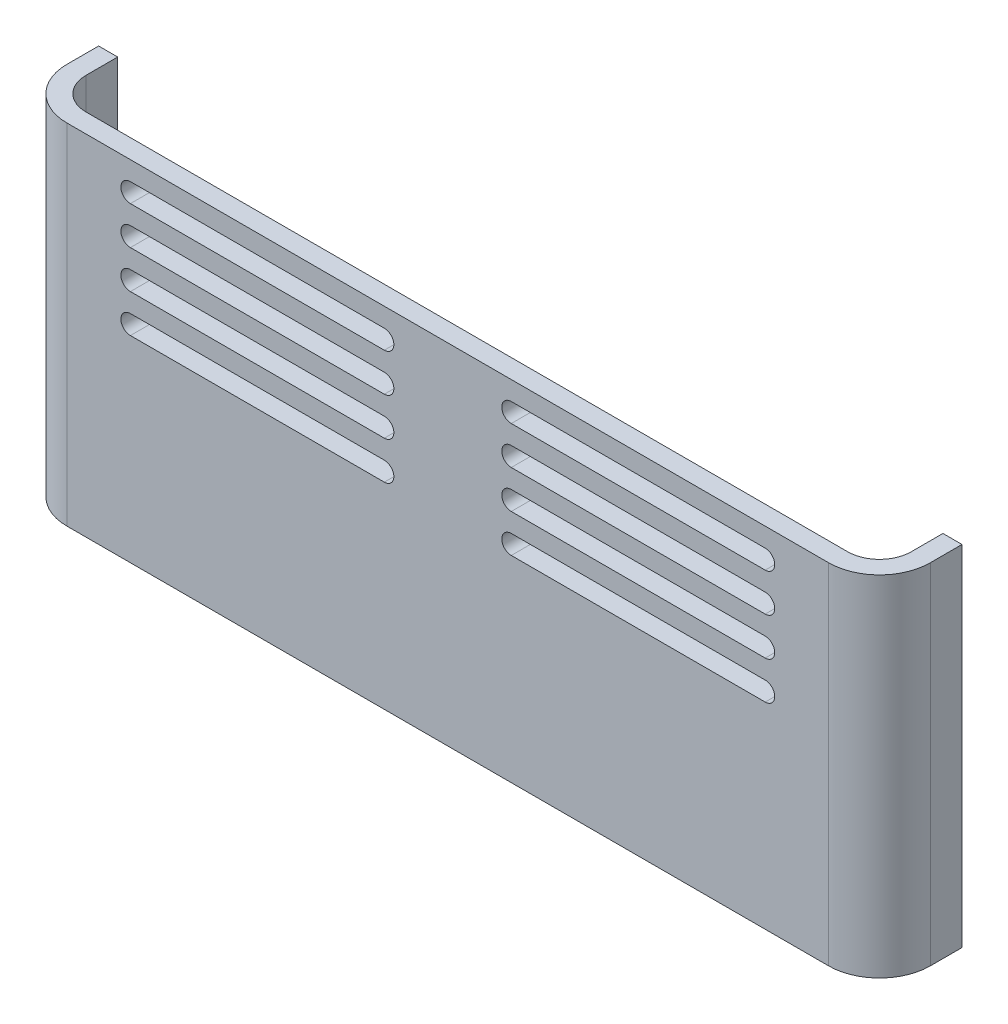
from build123d import *

# Parameters (mm, degrees)
BOSS_EXTRUDE1_DEPTH = 55
BOSS_EXTRUDE2_START = 15
SKETCH2_R           = 5
SKETCH2_R_2         = 2.75
BOSS_EXTRUDE2_DEPTH = 6
CUT_EXTRUDE1_START  = 15
SKETCH2_4_R         = 2.75
CUT_EXTRUDE1_DEPTH  = 4
SKETCH3_W           = 40
SKETCH3_H           = 3
CUT_EXTRUDE2_DEPTH  = 10
BOSS_EXTRUDE3_START = 15
SKETCH2_5_R         = 2.75
BOSS_EXTRUDE3_DEPTH = 1


with BuildPart() as part:
    # Sketch1 → Boss-Extrude1 (new body)
    with BuildSketch(Plane(origin=(0, 0, 0), x_dir=(1, 0, 0), z_dir=(0, 1, 0))):
        with BuildLine():
            Line((-3, 5), (-3, 10))
            Line((-3, 10), (0, 10))
            Line((0, 10), (0, 5))
            ThreePointArc((0, 5), (1.464466094, 1.464466094), (5, 0))
            Line((5, 0), (125, 0))
            ThreePointArc((125, 0), (128.535533906, 1.464466094), (130, 5))
            Line((130, 5), (130, 10))
            Line((130, 10), (133, 10))
            Line((133, 10), (133, 5))
            ThreePointArc((133, 5), (130.656854249, -0.656854249), (125, -3))
            Line((125, -3), (5, -3))
            ThreePointArc((5, -3), (-0.656854249, -0.656854249), (-3, 5))
        make_face()
    extrude(amount=BOSS_EXTRUDE1_DEPTH)

    # Sketch2 → Boss-Extrude2 (add)
    with BuildSketch(Plane(origin=(0, 0, 0), x_dir=(1, 0, 0), z_dir=(0, 1, 0)).offset(BOSS_EXTRUDE2_START)):
        with BuildLine():
            Line((5, 10), (0, 10))
            Line((0, 10), (0, 5))
            ThreePointArc((0, 5), (1.464466094, 8.535533906), (5, 10))
        make_face()
        with Locations((5, 5)):
            Circle(SKETCH2_R)
        with Locations((5, 5)):
            Circle(SKETCH2_R_2, mode=Mode.SUBTRACT)
        with BuildLine():
            Line((10, 0), (10, 5))
            ThreePointArc((10, 5), (8.535533906, 1.464466094), (5, 0))
            Line((5, 0), (10, 0))
        make_face()
        with BuildLine():
            Line((120, 5), (120, 0))
            Line((120, 0), (125, 0))
            ThreePointArc((125, 0), (121.464466094, 1.464466094), (120, 5))
        make_face()
        with Locations((125, 5)):
            Circle(SKETCH2_R)
        with Locations((125, 5)):
            Circle(SKETCH2_R_2, mode=Mode.SUBTRACT)
        with Locations((125, 5)):
            Circle(SKETCH2_R_2)
        with BuildLine():
            ThreePointArc((125, 10), (128.535533906, 8.535533906), (130, 5))
            Line((130, 5), (130, 10))
            Line((130, 10), (125, 10))
        make_face()
        with Locations((5, 5)):
            Circle(SKETCH2_R_2)
    extrude(amount=BOSS_EXTRUDE2_DEPTH)

    # Sketch2_4 → Cut-Extrude1 (cut)
    with BuildSketch(Plane(origin=(0, 0, 0), x_dir=(1, 0, 0), z_dir=(0, 1, 0)).offset(CUT_EXTRUDE1_START)):
        with Locations((5, 5)):
            Circle(SKETCH2_4_R)
        with Locations((125, 5)):
            Circle(SKETCH2_4_R)
    extrude(amount=CUT_EXTRUDE1_DEPTH, mode=Mode.SUBTRACT)

    # Sketch3 → Cut-Extrude2 (cut)
    with BuildSketch(Plane.XY):
        with BuildLine():
            ThreePointArc((55, 40), (56.5, 38.5), (55, 37))
            Line((55, 37), (15, 37))
            ThreePointArc((15, 37), (13.5, 38.5), (15, 40))
            Line((15, 40), (55, 40))
        make_face()
        with BuildLine():
            ThreePointArc((55, 46), (56.5, 44.5), (55, 43))
            Line((55, 43), (15, 43))
            ThreePointArc((15, 43), (13.5, 44.5), (15, 46))
            Line((15, 46), (55, 46))
        make_face()
        with BuildLine():
            Line((115, 37), (75, 37))
            ThreePointArc((75, 37), (73.5, 38.5), (75, 40))
            Line((75, 40), (115, 40))
            ThreePointArc((115, 40), (116.5, 38.5), (115, 37))
        make_face()
        with BuildLine():
            Line((115, 43), (75, 43))
            ThreePointArc((75, 43), (73.5, 44.5), (75, 46))
            Line((75, 46), (115, 46))
            ThreePointArc((115, 46), (116.5, 44.5), (115, 43))
        make_face()
        with Locations((95, 50.5)):
            Rectangle(SKETCH3_W, SKETCH3_H)
        with Locations((35, 50.5)):
            Rectangle(SKETCH3_W, SKETCH3_H)
        with BuildLine():
            ThreePointArc((15, 49), (13.5, 50.5), (15, 52))
            Line((15, 52), (15, 49))
        make_face()
        with BuildLine():
            ThreePointArc((55, 52), (56.5, 50.5), (55, 49))
            Line((55, 49), (55, 52))
        make_face()
        with BuildLine():
            Line((75, 52), (75, 49))
            ThreePointArc((75, 49), (73.5, 50.5), (75, 52))
        make_face()
        with BuildLine():
            Line((115, 52), (115, 49))
            ThreePointArc((115, 49), (116.5, 50.5), (115, 52))
        make_face()
        with BuildLine():
            ThreePointArc((55, 34), (56.5, 32.5), (55, 31))
            Line((55, 31), (15, 31))
            ThreePointArc((15, 31), (13.5, 32.5), (15, 34))
            Line((15, 34), (55, 34))
        make_face()
        with BuildLine():
            Line((115, 31), (75, 31))
            ThreePointArc((75, 31), (73.5, 32.5), (75, 34))
            Line((75, 34), (115, 34))
            ThreePointArc((115, 34), (116.5, 32.5), (115, 31))
        make_face()
    extrude(amount=CUT_EXTRUDE2_DEPTH, mode=Mode.SUBTRACT)

    # Sketch2_5 → Boss-Extrude3 (add)
    with BuildSketch(Plane(origin=(0, 0, 0), x_dir=(1, 0, 0), z_dir=(0, 1, 0)).offset(BOSS_EXTRUDE3_START)):
        with Locations((5, 5)):
            Circle(SKETCH2_5_R)
        with Locations((125, 5)):
            Circle(SKETCH2_5_R)
    extrude(amount=BOSS_EXTRUDE3_DEPTH)


solid = part.part
